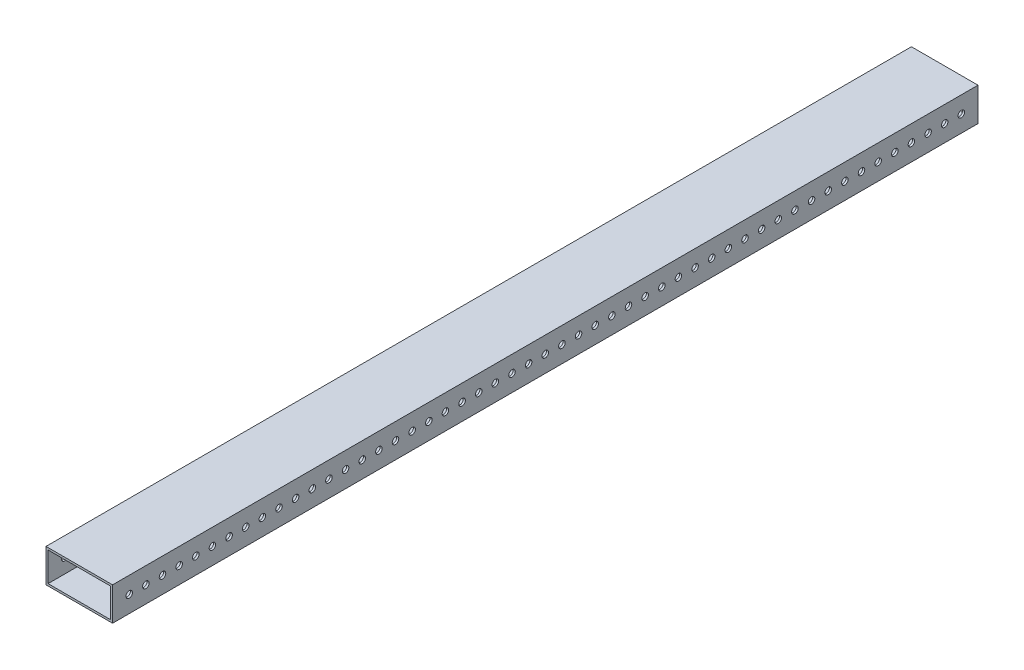
from build123d import *

# Parameters (mm, degrees)
SKETCH1_W           = 50.8
SKETCH1_H           = 25.4
SKETCH1_W_2         = 47.625
SKETCH1_H_2         = 22.225
BOSS_EXTRUDE1_DEPTH = 660.4
SKETCH2_R           = 2.4892
CUT_EXTRUDE1_DEPTH  = 51.8


with BuildPart() as part:
    # Sketch1 → Boss-Extrude1 (new body)
    with BuildSketch(Plane.XY):
        with Locations((25.4, 12.7)):
            Rectangle(SKETCH1_W, SKETCH1_H)
        with Locations((25.4, 12.7)):
            Rectangle(SKETCH1_W_2, SKETCH1_H_2, mode=Mode.SUBTRACT)
    extrude(amount=BOSS_EXTRUDE1_DEPTH)

    # Sketch2 → Cut-Extrude1 (cut, through all)
    with BuildSketch(Plane.ZY):
        with Locations((12.7, 12.7)):
            Circle(SKETCH2_R)
        with Locations((25.4, 12.7)):
            Circle(SKETCH2_R)
        with Locations((38.1, 12.7)):
            Circle(SKETCH2_R)
        with Locations((50.8, 12.7)):
            Circle(SKETCH2_R)
        with Locations((63.5, 12.7)):
            Circle(SKETCH2_R)
        with Locations((76.2, 12.7)):
            Circle(SKETCH2_R)
        with Locations((88.9, 12.7)):
            Circle(SKETCH2_R)
        with Locations((101.6, 12.7)):
            Circle(SKETCH2_R)
        with Locations((114.3, 12.7)):
            Circle(SKETCH2_R)
        with Locations((127, 12.7)):
            Circle(SKETCH2_R)
        with Locations((139.7, 12.7)):
            Circle(SKETCH2_R)
        with Locations((152.4, 12.7)):
            Circle(SKETCH2_R)
        with Locations((165.1, 12.7)):
            Circle(SKETCH2_R)
        with Locations((177.8, 12.7)):
            Circle(SKETCH2_R)
        with Locations((190.5, 12.7)):
            Circle(SKETCH2_R)
        with Locations((203.2, 12.7)):
            Circle(SKETCH2_R)
        with Locations((215.9, 12.7)):
            Circle(SKETCH2_R)
        with Locations((228.6, 12.7)):
            Circle(SKETCH2_R)
        with Locations((241.3, 12.7)):
            Circle(SKETCH2_R)
        with Locations((254, 12.7)):
            Circle(SKETCH2_R)
        with Locations((266.7, 12.7)):
            Circle(SKETCH2_R)
        with Locations((279.4, 12.7)):
            Circle(SKETCH2_R)
        with Locations((292.1, 12.7)):
            Circle(SKETCH2_R)
        with Locations((304.8, 12.7)):
            Circle(SKETCH2_R)
        with Locations((317.5, 12.7)):
            Circle(SKETCH2_R)
        with Locations((330.2, 12.7)):
            Circle(SKETCH2_R)
        with Locations((342.9, 12.7)):
            Circle(SKETCH2_R)
        with Locations((355.6, 12.7)):
            Circle(SKETCH2_R)
        with Locations((368.3, 12.7)):
            Circle(SKETCH2_R)
        with Locations((381, 12.7)):
            Circle(SKETCH2_R)
        with Locations((393.7, 12.7)):
            Circle(SKETCH2_R)
        with Locations((406.4, 12.7)):
            Circle(SKETCH2_R)
        with Locations((419.1, 12.7)):
            Circle(SKETCH2_R)
        with Locations((431.8, 12.7)):
            Circle(SKETCH2_R)
        with Locations((444.5, 12.7)):
            Circle(SKETCH2_R)
        with Locations((457.2, 12.7)):
            Circle(SKETCH2_R)
        with Locations((469.9, 12.7)):
            Circle(SKETCH2_R)
        with Locations((482.6, 12.7)):
            Circle(SKETCH2_R)
        with Locations((495.3, 12.7)):
            Circle(SKETCH2_R)
        with Locations((508, 12.7)):
            Circle(SKETCH2_R)
        with Locations((520.7, 12.7)):
            Circle(SKETCH2_R)
        with Locations((533.4, 12.7)):
            Circle(SKETCH2_R)
        with Locations((546.1, 12.7)):
            Circle(SKETCH2_R)
        with Locations((558.8, 12.7)):
            Circle(SKETCH2_R)
        with Locations((571.5, 12.7)):
            Circle(SKETCH2_R)
        with Locations((584.2, 12.7)):
            Circle(SKETCH2_R)
        with Locations((596.9, 12.7)):
            Circle(SKETCH2_R)
        with Locations((609.6, 12.7)):
            Circle(SKETCH2_R)
        with Locations((622.3, 12.7)):
            Circle(SKETCH2_R)
        with Locations((635, 12.7)):
            Circle(SKETCH2_R)
        with Locations((647.7, 12.7)):
            Circle(SKETCH2_R)
    extrude(amount=-CUT_EXTRUDE1_DEPTH, mode=Mode.SUBTRACT)


solid = part.part
